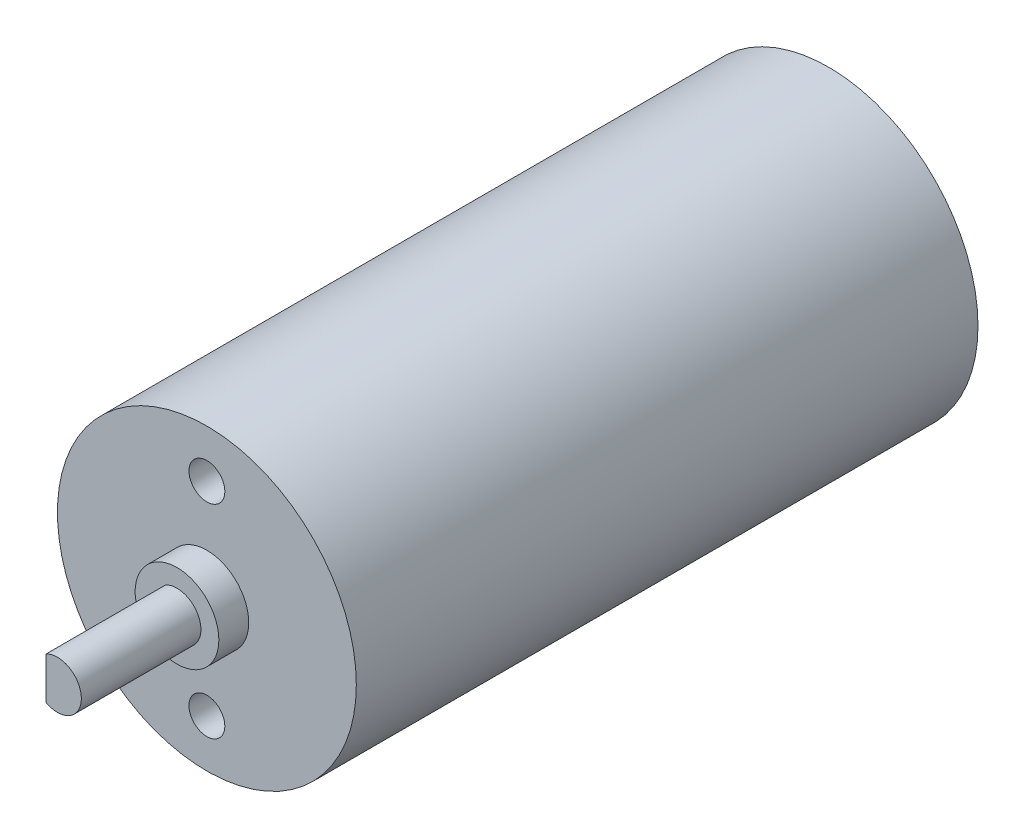
from build123d import *

# Parameters (mm, degrees)
SKETCH_1_R          = 12.5
EXTRUDE_1_DEPTH     = 52
SKETCH_2_R          = 3.5
EXTRUDE_2_DEPTH     = 2.5
SKETCH_3_R          = 2
EXTRUDE_3_DEPTH     = 10
CUT_EXTRUDE_1_DEPTH = 10
SKETCH_5_R          = 1.5
CUT_EXTRUDE_2_DEPTH = 7


with BuildPart() as part:
    # 草图1 → 凸台-拉伸1 (new body)
    with BuildSketch(Plane.XY):
        Circle(SKETCH_1_R)
    extrude(amount=EXTRUDE_1_DEPTH)

    # 草图2 → 凸台-拉伸2 (add)
    with BuildSketch(Plane.XY.offset(52)):
        Circle(SKETCH_2_R)
    extrude(amount=EXTRUDE_2_DEPTH)

    # 草图3 → 凸台-拉伸3 (add)
    with BuildSketch(Plane.XY.offset(54.5)):
        Circle(SKETCH_3_R)
    extrude(amount=EXTRUDE_3_DEPTH)

    # 草图4 → 切除-拉伸1 (cut)
    with BuildSketch(Plane.XY.offset(64.5)):
        with BuildLine():
            Line((-0.957908231, -1.755679874), (-0.957908231, 1.755679874))
            ThreePointArc((-0.957908231, 1.755679874), (-2, 0), (-0.957908231, -1.755679874))
        make_face()
    extrude(amount=-CUT_EXTRUDE_1_DEPTH, mode=Mode.SUBTRACT)

    # 草图5 → 切除-拉伸2 (cut)
    with BuildSketch(Plane.XY.offset(52)):
        with Locations((0, 8.5)):
            Circle(SKETCH_5_R)
        with Locations((0, -8.5)):
            Circle(SKETCH_5_R)
    extrude(amount=-CUT_EXTRUDE_2_DEPTH, mode=Mode.SUBTRACT)


solid = part.part
